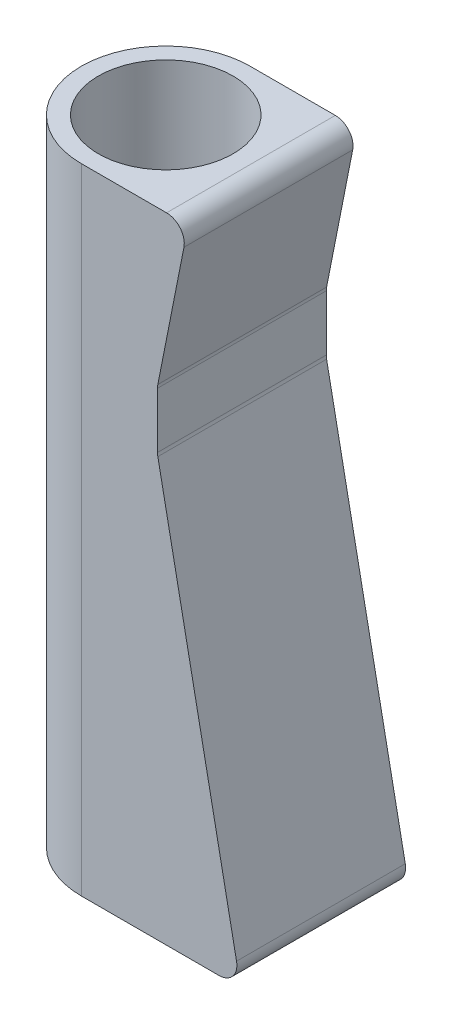
from build123d import *

# Parameters (mm, degrees)
SKETCH1_R           = 14.2875
SKETCH1_R_2         = 11.4125
BOSS_EXTRUDE1_DEPTH = 152.4
SKETCH2_W           = 28.575
SKETCH2_H           = 152.4
BOSS_EXTRUDE2_DEPTH = 12.7
BOSS_EXTRUDE3_DEPTH = 152.4
CUT_EXTRUDE1_DEPTH  = 29.575
FILLET1_R           = 3
SKETCH6_W           = 50
SKETCH6_H           = 45
CUT_EXTRUDE2_DEPTH  = 82
FILLET2_R           = 3


with BuildPart() as part:
    # Sketch1 → Boss-Extrude1 (new body)
    with BuildSketch(Plane(origin=(0, 0, 0), x_dir=(1, 0, 0), z_dir=(0, 1, 0))):
        Circle(SKETCH1_R)
        Circle(SKETCH1_R_2, mode=Mode.SUBTRACT)
    extrude(amount=BOSS_EXTRUDE1_DEPTH)



with BuildPart() as body_2:
    # Sketch2 → Boss-Extrude2 (new body)
    with BuildSketch(Plane(origin=(14.2875, 0, 0), x_dir=(0, 0, -1), z_dir=(1, 0, 0))):
        with Locations((0, 76.2)):
            Rectangle(SKETCH2_W, SKETCH2_H)
    extrude(amount=BOSS_EXTRUDE2_DEPTH)


with BuildPart() as part_1:
    add(part.part)

    add(body_2.part)  # Boss-Extrude3 merges body 2
    # Sketch3 → Boss-Extrude3 (add, through all)
    with BuildSketch(Plane(origin=(0, 152.4, 0), x_dir=(1, 0, 0), z_dir=(0, 1, 0))):
        with BuildLine():
            Line((14.2875, -14.2875), (0, -14.2875))
            ThreePointArc((0, -14.2875), (14.2875, 0), (0, 14.2875))
            Line((0, 14.2875), (14.2875, 14.2875))
            Line((14.2875, 14.2875), (26.9875, 14.2875))
            Line((26.9875, 14.2875), (26.9875, -14.2875))
            Line((26.9875, -14.2875), (14.2875, -14.2875))
        make_face()
    extrude(amount=-BOSS_EXTRUDE3_DEPTH)

    # Sketch5 → Cut-Extrude1 (cut, through all)
    with BuildSketch(Plane.XY.offset(14.2875)):
        Polygon((26.9875, 0), (12.897222949, 71.2), (12.897222949, 81.2), (26.9875, 152.4), align=None)
    extrude(amount=-CUT_EXTRUDE1_DEPTH, mode=Mode.SUBTRACT)

    # Fillet1
    fillet1_edges = [part_1.edges().sort_by_distance(p)[0] for p in [
        (26.9875, 0, 0),
        (26.9875, 152.4, 0),
        (12.897222949, 71.2, 0),
        (12.897222949, 81.2, 0),
    ]]
    fillet(fillet1_edges, radius=FILLET1_R)

    # Sketch6 → Cut-Extrude2 (cut)
    with BuildSketch(Plane.XY.offset(14.2875)):
        with Locations((9.7125, 129.9)):
            Rectangle(SKETCH6_W, SKETCH6_H)
    extrude(amount=-CUT_EXTRUDE2_DEPTH, mode=Mode.SUBTRACT)

    # Fillet2
    fillet2_edges = [part_1.edges().sort_by_distance(p)[0] for p in [
        (18.082128268, 107.4, 0),
    ]]
    fillet(fillet2_edges, radius=FILLET2_R)


solid = part_1.part
